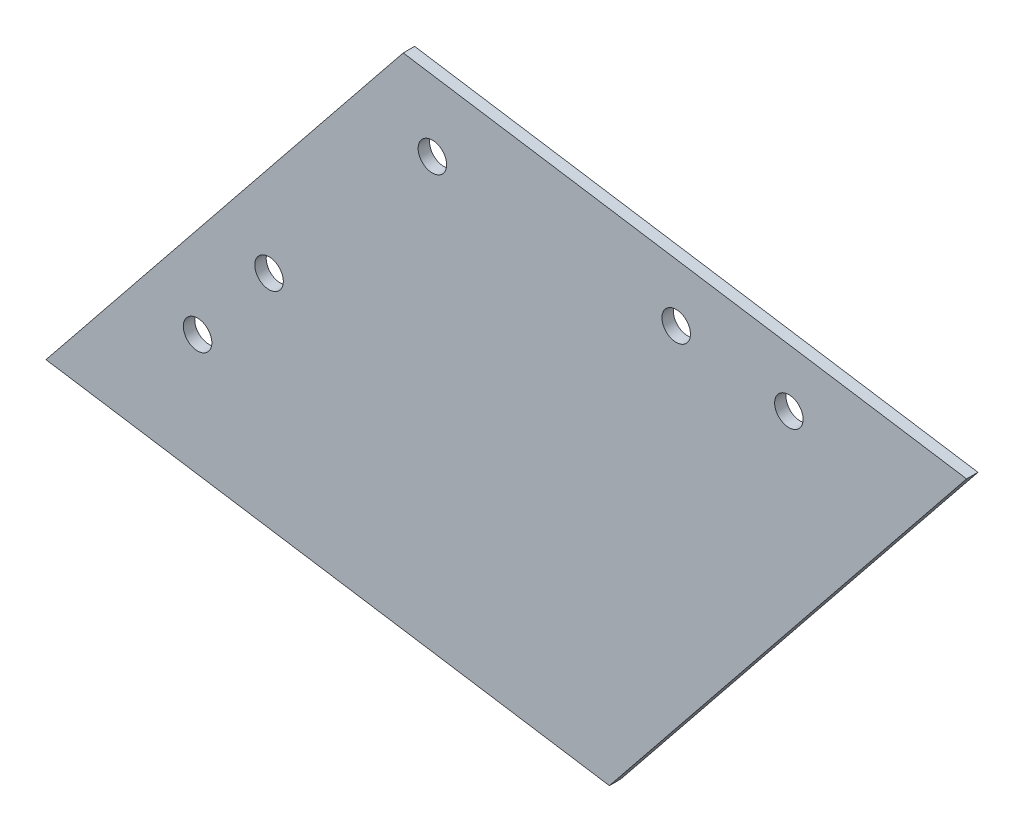
from build123d import *

# Parameters (mm, degrees)
BOSS_EXTRUDE1_DEPTH = 2
SKETCH2_R           = 2.5
CUT_EXTRUDE1_DEPTH  = 6
SKETCH3_R           = 2.5
CUT_EXTRUDE2_DEPTH  = 6
SKETCH4_R           = 2.5
CUT_EXTRUDE3_DEPTH  = 6
SKETCH5_R           = 2.5
CUT_EXTRUDE4_DEPTH  = 6
SKETCH6_R           = 2.5
CUT_EXTRUDE5_DEPTH  = 6


with BuildPart() as part:
    # Sketch1 → Boss-Extrude1 (new body)
    with BuildSketch(Plane.XY):
        Polygon((0, 0), (62.662776372, 77.931870614), (161.485144274, 62.630249712), (98.822367902, -15.301620902), align=None)
    extrude(amount=BOSS_EXTRUDE1_DEPTH)

    # Sketch2 → Cut-Extrude1 (cut)
    with BuildSketch(Plane(origin=(0, 0, 0), x_dir=(-1, 0, 0), z_dir=(0, 0, -1))):
        with Locations((-39.124575247, 32.69965767)):
            Circle(SKETCH2_R)
    extrude(amount=-CUT_EXTRUDE1_DEPTH, mode=Mode.SUBTRACT)

    # Sketch3 → Cut-Extrude2 (cut)
    with BuildSketch(Plane(origin=(0, 0, 0), x_dir=(-1, 0, 0), z_dir=(0, 0, -1))):
        with Locations((-26.592019973, 17.113283547)):
            Circle(SKETCH3_R)
    extrude(amount=-CUT_EXTRUDE2_DEPTH, mode=Mode.SUBTRACT)

    # Sketch4 → Cut-Extrude3 (cut)
    with BuildSketch(Plane(origin=(0, 0, 0), x_dir=(-1, 0, 0), z_dir=(0, 0, -1))):
        with Locations((-130.308271813, 57.338499192)):
            Circle(SKETCH4_R)
    extrude(amount=-CUT_EXTRUDE3_DEPTH, mode=Mode.SUBTRACT)

    # Sketch5 → Cut-Extrude4 (cut)
    with BuildSketch(Plane(origin=(0, 0, 0), x_dir=(-1, 0, 0), z_dir=(0, 0, -1))):
        with Locations((-110.543798232, 60.398823373)):
            Circle(SKETCH5_R)
    extrude(amount=-CUT_EXTRUDE4_DEPTH, mode=Mode.SUBTRACT)

    # Sketch6 → Cut-Extrude5 (cut)
    with BuildSketch(Plane(origin=(0, 0, 0), x_dir=(-1, 0, 0), z_dir=(0, 0, -1))):
        with Locations((-67.776514838, 64.746663819)):
            Circle(SKETCH6_R)
    extrude(amount=-CUT_EXTRUDE5_DEPTH, mode=Mode.SUBTRACT)


solid = part.part
